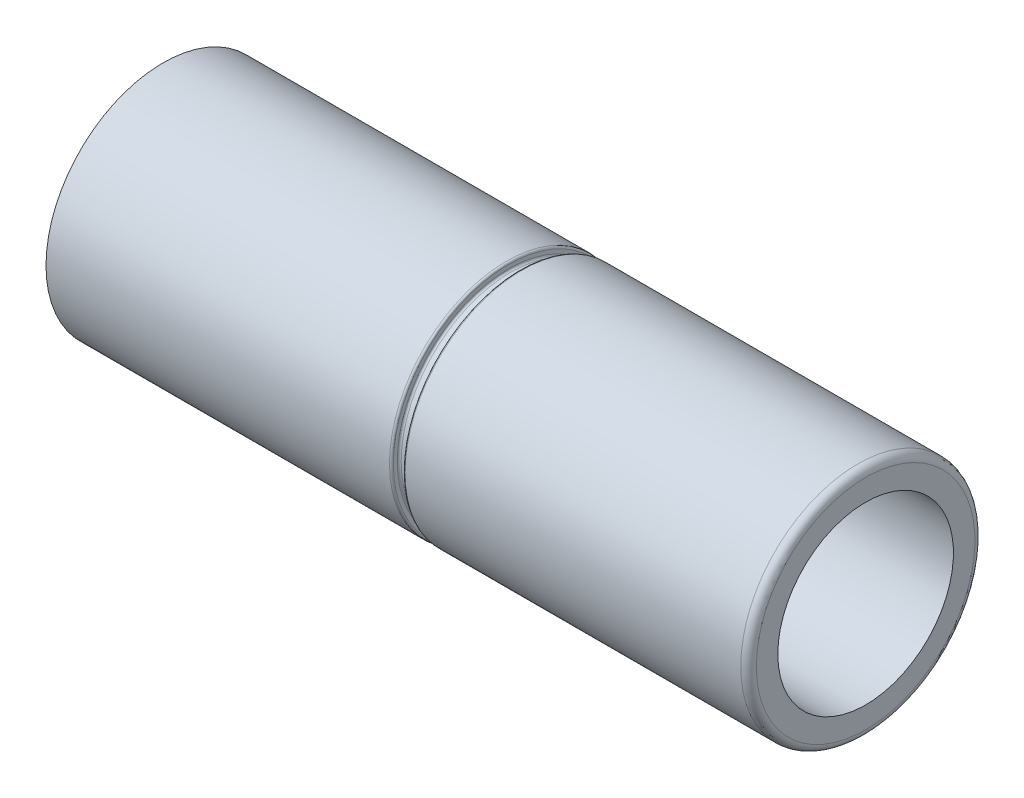
from build123d import *

# Parameters (mm, degrees)
FILLET2_R = 0.2


with BuildPart() as part:
    # Sketch2 → Revolve1 (revolve)
    with BuildSketch(Plane(origin=(0, 0, 0), x_dir=(1, 0, 0), z_dir=(0, 1, 0))):
        with BuildLine():
            Line((18, 2.25), (18, 3))
            Line((18, 3), (9.2, 3))
            ThreePointArc((9.2, 3), (9.164644661, 2.985355339), (9.15, 2.95))
            Line((9.15, 2.95), (9.15, 2.85))
            ThreePointArc((9.15, 2.85), (9.135355339, 2.814644661), (9.1, 2.8))
            Line((9.1, 2.8), (8.9, 2.8))
            ThreePointArc((8.9, 2.8), (8.864644661, 2.814644661), (8.85, 2.85))
            Line((8.85, 2.85), (8.85, 2.95))
            ThreePointArc((8.85, 2.95), (8.835355339, 2.985355339), (8.8, 3))
            Line((8.8, 3), (0, 3))
            Line((0, 3), (0, 2.25))
            Line((0, 2.25), (18, 2.25))
        make_face()
    revolve(axis=Axis((0, 0, 0), (1, 0, 0)))

    # Fillet2
    fillet2_edges = [part.edges().sort_by_distance(p)[0] for p in [
        (18, 0, 3),
    ]]
    fillet(fillet2_edges, radius=FILLET2_R)


solid = part.part
